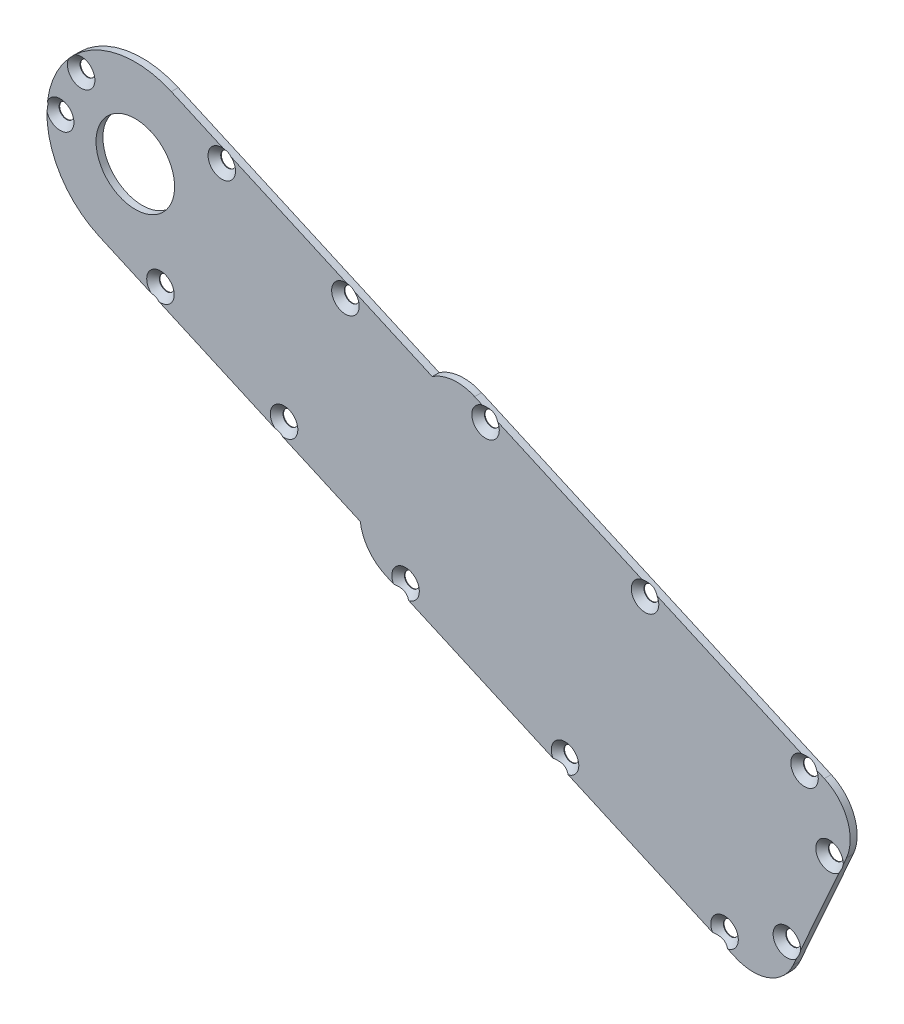
from build123d import *

# Parameters (mm, degrees)
SKETCH1_R                                      = 1.7
BOSS_EXTRUDE1_DEPTH                            = 1.5875
SKETCH2_R                                      = 9
CUT_EXTRUDE1_DEPTH                             = 2.5875
CSK_FOR_M3_FLAT_HEAD_MACHINE_SCREW1_AT_2_COUNT = 2
CSK_FOR_M3_FLAT_HEAD_MACHINE_SCREW1_AT_2_PITCH = 11.799694945
CSK_FOR_M3_FLAT_HEAD_MACHINE_SCREW1_AT_3_COUNT = 2
CSK_FOR_M3_FLAT_HEAD_MACHINE_SCREW1_AT_3_PITCH = 38.059706694
CSK_FOR_M3_FLAT_HEAD_MACHINE_SCREW1_AT_4_COUNT = 2
CSK_FOR_M3_FLAT_HEAD_MACHINE_SCREW1_AT_4_PITCH = 65.441137915
CSK_FOR_M3_FLAT_HEAD_MACHINE_SCREW1_AT_5_COUNT = 2
CSK_FOR_M3_FLAT_HEAD_MACHINE_SCREW1_AT_5_PITCH = 98.21142491
CSK_FOR_M3_FLAT_HEAD_MACHINE_SCREW1_AT_6_COUNT = 2
CSK_FOR_M3_FLAT_HEAD_MACHINE_SCREW1_AT_6_PITCH = 136.991721698
CSK_FOR_M3_FLAT_HEAD_MACHINE_SCREW1_AT_7_COUNT = 2
CSK_FOR_M3_FLAT_HEAD_MACHINE_SCREW1_AT_7_PITCH = 176.317837002
CSK_FOR_M3_FLAT_HEAD_MACHINE_SCREW1_AT_8_COUNT = 2
CSK_FOR_M3_FLAT_HEAD_MACHINE_SCREW1_AT_8_PITCH = 185.829698762
CSK_FOR_M3_FLAT_HEAD_MACHINE_SCREW1_AT_9_COUNT = 2
CSK_FOR_M3_FLAT_HEAD_MACHINE_SCREW1_AT_9_PITCH = 185.066161853
CSK_FOR_M3_FLAT_HEAD_MACHINE_SCREW1_AT_1_COUNT = 2
CSK_FOR_M3_FLAT_HEAD_MACHINE_SCREW1_AT_1_PITCH = 174.805587361
CSK_FOR_M3_FLAT_HEAD_MACHINE_SCREW1_2_COUNT    = 2
CSK_FOR_M3_FLAT_HEAD_MACHINE_SCREW1_2_PITCH    = 135.039792437
CSK_FOR_M3_FLAT_HEAD_MACHINE_SCREW1_3_COUNT    = 2
CSK_FOR_M3_FLAT_HEAD_MACHINE_SCREW1_3_PITCH    = 95.46987855
CSK_FOR_M3_FLAT_HEAD_MACHINE_SCREW1_4_COUNT    = 2
CSK_FOR_M3_FLAT_HEAD_MACHINE_SCREW1_4_PITCH    = 62.253136917
CSK_FOR_M3_FLAT_HEAD_MACHINE_SCREW1_5_COUNT    = 2
CSK_FOR_M3_FLAT_HEAD_MACHINE_SCREW1_5_PITCH    = 32.271532316


with BuildPart() as part:
    # Sketch1 → Boss-Extrude1 (new body)
    with BuildSketch(Plane.XY):
        with BuildLine():
            Line((-21.913942314, 59.552395428), (-102.015642796, 95.25964371))
            ThreePointArc((-102.015642796, 95.25964371), (-106.983028684, 96.085831021), (-111.723245825, 94.386463641))
            Line((-111.723245825, 94.386463641), (-171.498000771, 121.032489918))
            ThreePointArc((-171.498000771, 121.032489918), (-198.238379477, 110.781775471), (-187.98766503, 84.041396765))
            Line((-187.98766503, 84.041396765), (-128.212910083, 57.395370488))
            ThreePointArc((-128.212910083, 57.395370488), (-126.308202352, 52.73386896), (-122.373252992, 49.591627472))
            Line((-122.373252992, 49.591627472), (-42.27155251, 13.884379189))
            ThreePointArc((-42.27155251, 13.884379189), (-34.620598521, 13.6805488), (-29.066427223, 18.946460398))
            Line((-29.066427223, 18.946460398), (-16.851861106, 46.347270141))
            ThreePointArc((-16.851861106, 46.347270141), (-16.648030717, 53.99822413), (-21.913942314, 59.552395428))
        make_face()
        with Locations((-99.517086056, 91.408706914)):
            Circle(SKETCH1_R, mode=Mode.SUBTRACT)
        with Locations((-62.982673065, 75.122618757)):
            Circle(SKETCH1_R, mode=Mode.SUBTRACT)
        with Locations((-26.448260075, 58.836530601)):
            Circle(SKETCH1_R, mode=Mode.SUBTRACT)
        with Locations((-20.722062659, 44.787930558)):
            Circle(SKETCH1_R, mode=Mode.SUBTRACT)
        with Locations((-30.493715553, 22.867282764)):
            Circle(SKETCH1_R, mode=Mode.SUBTRACT)
        with Locations((-44.77010925, 17.735315986)):
            Circle(SKETCH1_R, mode=Mode.SUBTRACT)
        with Locations((-81.304522241, 34.021404143)):
            Circle(SKETCH1_R, mode=Mode.SUBTRACT)
        with Locations((-117.838935231, 50.307492299)):
            Circle(SKETCH1_R, mode=Mode.SUBTRACT)
        with Locations((-131.618242769, 99.970559768)):
            Circle(SKETCH1_R, mode=Mode.SUBTRACT)
        with Locations((-145.664993804, 68.459628564)):
            Circle(SKETCH1_R, mode=Mode.SUBTRACT)
        with Locations((-173.979163871, 81.081346885)):
            Circle(SKETCH1_R, mode=Mode.SUBTRACT)
        with Locations((-159.932412836, 112.592278089)):
            Circle(SKETCH1_R, mode=Mode.SUBTRACT)
        with Locations((-192.145991763, 114.525444092)):
            Circle(SKETCH1_R, mode=Mode.SUBTRACT)
        with Locations((-196.950263565, 103.748070885)):
            Circle(SKETCH1_R, mode=Mode.SUBTRACT)
    extrude(amount=BOSS_EXTRUDE1_DEPTH)

    # Sketch2 → Cut-Extrude1 (cut, through all)
    with BuildSketch(Plane(origin=(0, 0, 0), x_dir=(-1, 0, 0), z_dir=(0, 0, -1))):
        with Locations((179.7428329, 102.536943342)):
            Circle(SKETCH2_R)
    extrude(amount=-CUT_EXTRUDE1_DEPTH, mode=Mode.SUBTRACT)

    # Sketch3 → CSK for M3 Flat Head Machine Screw1 (revolve, cut)
    with BuildSketch(Plane(origin=(-192.145991763, 114.525444092, 1.5875), x_dir=(0, -1, 0), z_dir=(1, 0, 0))):
        Polygon((0, 0), (0, 1.5875), (1.7, 1.5875), (1.7, 1.45), (3.15, 0), align=None)
    csk_for_m3_flat_head_machine_screw1 = revolve(axis=Axis((-192.145991763, 114.525444092, 7.9375), (0, 0, -1)), mode=Mode.SUBTRACT)

    # CSK for M3 Flat Head Machine Screw1 at 2: CSK for M3 Flat Head Machine Screw1 ×2
    with Locations(*[Vector(-0.407152204, -0.913360325, 0) * (i * CSK_FOR_M3_FLAT_HEAD_MACHINE_SCREW1_AT_2_PITCH) for i in range(1, CSK_FOR_M3_FLAT_HEAD_MACHINE_SCREW1_AT_2_COUNT)]):
        add(csk_for_m3_flat_head_machine_screw1, mode=Mode.SUBTRACT)

    # CSK for M3 Flat Head Machine Screw1 at 3: CSK for M3 Flat Head Machine Screw1 ×2
    with Locations(*[Vector(0.477324432, -0.87872714, 0) * (i * CSK_FOR_M3_FLAT_HEAD_MACHINE_SCREW1_AT_3_PITCH) for i in range(1, CSK_FOR_M3_FLAT_HEAD_MACHINE_SCREW1_AT_3_COUNT)]):
        add(csk_for_m3_flat_head_machine_screw1, mode=Mode.SUBTRACT)

    # CSK for M3 Flat Head Machine Screw1 at 4: CSK for M3 Flat Head Machine Screw1 ×2
    with Locations(*[Vector(0.710271848, -0.703927483, 0) * (i * CSK_FOR_M3_FLAT_HEAD_MACHINE_SCREW1_AT_4_PITCH) for i in range(1, CSK_FOR_M3_FLAT_HEAD_MACHINE_SCREW1_AT_4_COUNT)]):
        add(csk_for_m3_flat_head_machine_screw1, mode=Mode.SUBTRACT)

    # CSK for M3 Flat Head Machine Screw1 at 5: CSK for M3 Flat Head Machine Screw1 ×2
    with Locations(*[Vector(0.756602978, -0.653874555, 0) * (i * CSK_FOR_M3_FLAT_HEAD_MACHINE_SCREW1_AT_5_PITCH) for i in range(1, CSK_FOR_M3_FLAT_HEAD_MACHINE_SCREW1_AT_5_COUNT)]):
        add(csk_for_m3_flat_head_machine_screw1, mode=Mode.SUBTRACT)

    # CSK for M3 Flat Head Machine Screw1 at 6: CSK for M3 Flat Head Machine Screw1 ×2
    with Locations(*[Vector(0.809110712, -0.587656239, 0) * (i * CSK_FOR_M3_FLAT_HEAD_MACHINE_SCREW1_AT_6_PITCH) for i in range(1, CSK_FOR_M3_FLAT_HEAD_MACHINE_SCREW1_AT_6_COUNT)]):
        add(csk_for_m3_flat_head_machine_screw1, mode=Mode.SUBTRACT)

    # CSK for M3 Flat Head Machine Screw1 at 7: CSK for M3 Flat Head Machine Screw1 ×2
    with Locations(*[Vector(0.835853508, -0.548952561, 0) * (i * CSK_FOR_M3_FLAT_HEAD_MACHINE_SCREW1_AT_7_PITCH) for i in range(1, CSK_FOR_M3_FLAT_HEAD_MACHINE_SCREW1_AT_7_COUNT)]):
        add(csk_for_m3_flat_head_machine_screw1, mode=Mode.SUBTRACT)

    # CSK for M3 Flat Head Machine Screw1 at 8: CSK for M3 Flat Head Machine Screw1 ×2
    with Locations(*[Vector(0.869894733, -0.493237421, 0) * (i * CSK_FOR_M3_FLAT_HEAD_MACHINE_SCREW1_AT_8_PITCH) for i in range(1, CSK_FOR_M3_FLAT_HEAD_MACHINE_SCREW1_AT_8_COUNT)]):
        add(csk_for_m3_flat_head_machine_screw1, mode=Mode.SUBTRACT)

    # CSK for M3 Flat Head Machine Screw1 at 9: CSK for M3 Flat Head Machine Screw1 ×2
    with Locations(*[Vector(0.926284564, -0.376824768, 0) * (i * CSK_FOR_M3_FLAT_HEAD_MACHINE_SCREW1_AT_9_PITCH) for i in range(1, CSK_FOR_M3_FLAT_HEAD_MACHINE_SCREW1_AT_9_COUNT)]):
        add(csk_for_m3_flat_head_machine_screw1, mode=Mode.SUBTRACT)

    # CSK for M3 Flat Head Machine Screw1 at 1: CSK for M3 Flat Head Machine Screw1 ×2
    with Locations(*[Vector(0.947897228, -0.318576279, 0) * (i * CSK_FOR_M3_FLAT_HEAD_MACHINE_SCREW1_AT_1_PITCH) for i in range(1, CSK_FOR_M3_FLAT_HEAD_MACHINE_SCREW1_AT_1_COUNT)]):
        add(csk_for_m3_flat_head_machine_screw1, mode=Mode.SUBTRACT)

    # CSK for M3 Flat Head Machine Screw1  2: CSK for M3 Flat Head Machine Screw1 ×2
    with Locations(*[Vector(0.956483392, -0.291786774, 0) * (i * CSK_FOR_M3_FLAT_HEAD_MACHINE_SCREW1_2_PITCH) for i in range(1, CSK_FOR_M3_FLAT_HEAD_MACHINE_SCREW1_2_COUNT)]):
        add(csk_for_m3_flat_head_machine_screw1, mode=Mode.SUBTRACT)

    # CSK for M3 Flat Head Machine Screw1  3: CSK for M3 Flat Head Machine Screw1 ×2
    with Locations(*[Vector(0.970242207, -0.242136447, 0) * (i * CSK_FOR_M3_FLAT_HEAD_MACHINE_SCREW1_3_PITCH) for i in range(1, CSK_FOR_M3_FLAT_HEAD_MACHINE_SCREW1_3_COUNT)]):
        add(csk_for_m3_flat_head_machine_screw1, mode=Mode.SUBTRACT)

    # CSK for M3 Flat Head Machine Screw1  4: CSK for M3 Flat Head Machine Screw1 ×2
    with Locations(*[Vector(0.972284322, -0.233801621, 0) * (i * CSK_FOR_M3_FLAT_HEAD_MACHINE_SCREW1_4_PITCH) for i in range(1, CSK_FOR_M3_FLAT_HEAD_MACHINE_SCREW1_4_COUNT)]):
        add(csk_for_m3_flat_head_machine_screw1, mode=Mode.SUBTRACT)

    # CSK for M3 Flat Head Machine Screw1  5: CSK for M3 Flat Head Machine Screw1 ×2
    with Locations(*[Vector(0.998204195, -0.059903136, 0) * (i * CSK_FOR_M3_FLAT_HEAD_MACHINE_SCREW1_5_PITCH) for i in range(1, CSK_FOR_M3_FLAT_HEAD_MACHINE_SCREW1_5_COUNT)]):
        add(csk_for_m3_flat_head_machine_screw1, mode=Mode.SUBTRACT)


solid = part.part
